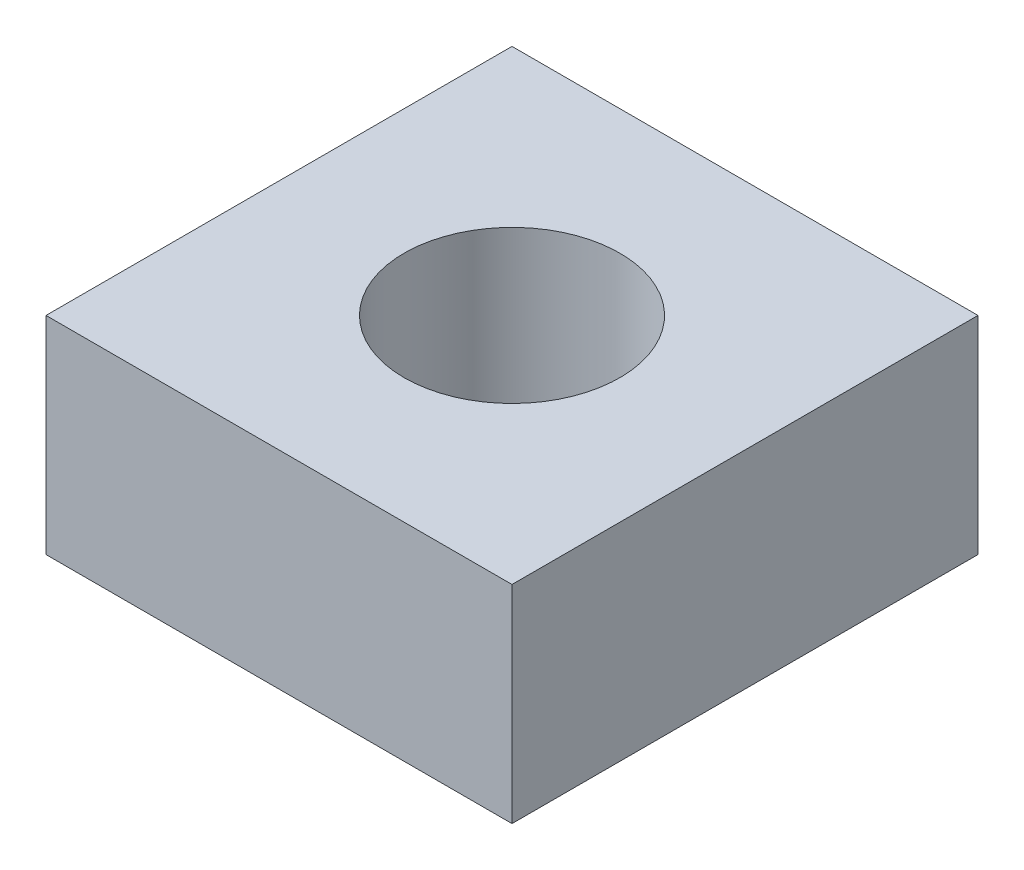
from build123d import *

# Parameters (mm, degrees)
SKETCH1_W             = 5.4
SKETCH1_H             = 5.4
BOSS_EXTRUDE1_DEPTH   = 2.4
M3X0_5_TAPPED_HOLE1_D = 2.5


with BuildPart() as part:
    # Sketch1 → Boss-Extrude1 (new body)
    with BuildSketch(Plane(origin=(0, 0, 0), x_dir=(1, 0, 0), z_dir=(0, 1, 0))):
        Rectangle(SKETCH1_W, SKETCH1_H)
    extrude(amount=BOSS_EXTRUDE1_DEPTH)

    # M3x0.5 Tapped Hole1 (through all)
    with Locations(Plane(origin=(0, 2.4, 0), x_dir=(1, 0, 0), z_dir=(0, 1, 0))):
        with Locations((0, 0)):
            Hole(M3X0_5_TAPPED_HOLE1_D / 2)


solid = part.part
